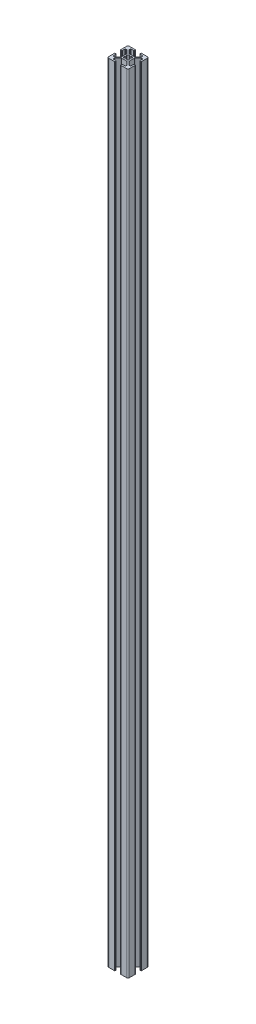
from build123d import *

# Parameters (mm, degrees)
C_PROGRAM_FILES_SOLIDWORKS_CORP_SOLIDWOR_DEPTH = 760


with BuildPart() as part:
    # Sketch11 → C_PROGRAM FILES_SOLIDWORKS CORP_SOLIDWOR (new body)
    with BuildSketch(Plane.XZ.offset(-380)):
        with BuildLine():
            Line((9.0094, 2.6289), (9.492, 2.6289))
            ThreePointArc((9.492, 2.6289), (9.851210245, 2.777689755), (10, 3.1369))
            Line((10, 3.1369), (10, 8.5014))
            ThreePointArc((10, 8.5014), (9.561070222, 9.561070222), (8.5014, 10))
            Line((8.5014, 10), (3.1369, 10))
            ThreePointArc((3.1369, 10), (2.777689755, 9.851210245), (2.6289, 9.492))
            Line((2.6289, 9.492), (2.6289, 9.0094))
            ThreePointArc((2.6289, 9.0094), (2.777689755, 8.650189755), (3.1369, 8.5014))
            Line((3.1369, 8.5014), (5.4864, 8.5014))
            ThreePointArc((5.4864, 8.5014), (5.845610245, 8.352610245), (5.9944, 7.9934))
            Line((5.9944, 7.9934), (5.9944, 7.264490712))
            ThreePointArc((5.9944, 7.264490712), (5.955730803, 7.070087528), (5.845610245, 6.905280467))
            Line((5.845610245, 6.905280467), (2.747686782, 3.807357004))
            ThreePointArc((2.747686782, 3.807357004), (2.582879721, 3.697236446), (2.388476537, 3.658567249))
            Line((2.388476537, 3.658567249), (-2.388476537, 3.658567249))
            ThreePointArc((-2.388476537, 3.658567249), (-2.582879721, 3.697236446), (-2.747686782, 3.807357004))
            Line((-2.747686782, 3.807357004), (-5.845610245, 6.905280467))
            ThreePointArc((-5.845610245, 6.905280467), (-5.955730803, 7.070087528), (-5.9944, 7.264490712))
            Line((-5.9944, 7.264490712), (-5.9944, 7.9934))
            ThreePointArc((-5.9944, 7.9934), (-5.845610245, 8.352610245), (-5.4864, 8.5014))
            Line((-5.4864, 8.5014), (-3.1369, 8.5014))
            ThreePointArc((-3.1369, 8.5014), (-2.777689755, 8.650189755), (-2.6289, 9.0094))
            Line((-2.6289, 9.0094), (-2.6289, 9.492))
            ThreePointArc((-2.6289, 9.492), (-2.777689755, 9.851210245), (-3.1369, 10))
            Line((-3.1369, 10), (-8.5014, 10))
            ThreePointArc((-8.5014, 10), (-9.561070222, 9.561070222), (-10, 8.5014))
            Line((-10, 8.5014), (-10, 3.1369))
            ThreePointArc((-10, 3.1369), (-9.851210245, 2.777689755), (-9.492, 2.6289))
            Line((-9.492, 2.6289), (-9.0094, 2.6289))
            ThreePointArc((-9.0094, 2.6289), (-8.650189755, 2.777689755), (-8.5014, 3.1369))
            Line((-8.5014, 3.1369), (-8.5014, 5.4864))
            ThreePointArc((-8.5014, 5.4864), (-8.352610245, 5.845610245), (-7.9934, 5.9944))
            Line((-7.9934, 5.9944), (-7.264490712, 5.9944))
            ThreePointArc((-7.264490712, 5.9944), (-7.070087528, 5.955730803), (-6.905280467, 5.845610245))
            Line((-6.905280467, 5.845610245), (-3.807357004, 2.747686782))
            ThreePointArc((-3.807357004, 2.747686782), (-3.697236446, 2.582879721), (-3.658567249, 2.388476537))
            Line((-3.658567249, 2.388476537), (-3.658567249, -2.388476537))
            ThreePointArc((-3.658567249, -2.388476537), (-3.697236446, -2.582879721), (-3.807357004, -2.747686782))
            Line((-3.807357004, -2.747686782), (-6.905280467, -5.845610245))
            ThreePointArc((-6.905280467, -5.845610245), (-7.070087528, -5.955730803), (-7.264490712, -5.9944))
            Line((-7.264490712, -5.9944), (-7.9934, -5.9944))
            ThreePointArc((-7.9934, -5.9944), (-8.352610245, -5.845610245), (-8.5014, -5.4864))
            Line((-8.5014, -5.4864), (-8.5014, -3.1369))
            ThreePointArc((-8.5014, -3.1369), (-8.650189755, -2.777689755), (-9.0094, -2.6289))
            Line((-9.0094, -2.6289), (-9.492, -2.6289))
            ThreePointArc((-9.492, -2.6289), (-9.851210245, -2.777689755), (-10, -3.1369))
            Line((-10, -3.1369), (-10, -8.5014))
            ThreePointArc((-10, -8.5014), (-9.561070222, -9.561070222), (-8.5014, -10))
            Line((-8.5014, -10), (-3.1369, -10))
            ThreePointArc((-3.1369, -10), (-2.777689755, -9.851210245), (-2.6289, -9.492))
            Line((-2.6289, -9.492), (-2.6289, -9.0094))
            ThreePointArc((-2.6289, -9.0094), (-2.777689755, -8.650189755), (-3.1369, -8.5014))
            Line((-3.1369, -8.5014), (-5.4864, -8.5014))
            ThreePointArc((-5.4864, -8.5014), (-5.845610245, -8.352610245), (-5.9944, -7.9934))
            Line((-5.9944, -7.9934), (-5.9944, -7.264490712))
            ThreePointArc((-5.9944, -7.264490712), (-5.955730803, -7.070087528), (-5.845610245, -6.905280467))
            Line((-5.845610245, -6.905280467), (-2.747686782, -3.807357004))
            ThreePointArc((-2.747686782, -3.807357004), (-2.582879721, -3.697236446), (-2.388476537, -3.658567249))
            Line((-2.388476537, -3.658567249), (2.388476537, -3.658567249))
            ThreePointArc((2.388476537, -3.658567249), (2.582879721, -3.697236446), (2.747686782, -3.807357004))
            Line((2.747686782, -3.807357004), (5.845610245, -6.905280467))
            ThreePointArc((5.845610245, -6.905280467), (5.955730803, -7.070087528), (5.9944, -7.264490712))
            Line((5.9944, -7.264490712), (5.9944, -7.9934))
            ThreePointArc((5.9944, -7.9934), (5.845610245, -8.352610245), (5.4864, -8.5014))
            Line((5.4864, -8.5014), (3.1369, -8.5014))
            ThreePointArc((3.1369, -8.5014), (2.777689755, -8.650189755), (2.6289, -9.0094))
            Line((2.6289, -9.0094), (2.6289, -9.492))
            ThreePointArc((2.6289, -9.492), (2.777689755, -9.851210245), (3.1369, -10))
            Line((3.1369, -10), (8.5014, -10))
            ThreePointArc((8.5014, -10), (9.561070222, -9.561070222), (10, -8.5014))
            Line((10, -8.5014), (10, -3.1369))
            ThreePointArc((10, -3.1369), (9.851210245, -2.777689755), (9.492, -2.6289))
            Line((9.492, -2.6289), (9.0094, -2.6289))
            ThreePointArc((9.0094, -2.6289), (8.650189755, -2.777689755), (8.5014, -3.1369))
            Line((8.5014, -3.1369), (8.5014, -5.4864))
            ThreePointArc((8.5014, -5.4864), (8.352610245, -5.845610245), (7.9934, -5.9944))
            Line((7.9934, -5.9944), (7.264490712, -5.9944))
            ThreePointArc((7.264490712, -5.9944), (7.070087528, -5.955730803), (6.905280467, -5.845610245))
            Line((6.905280467, -5.845610245), (3.807357004, -2.747686782))
            ThreePointArc((3.807357004, -2.747686782), (3.697236446, -2.582879721), (3.658567249, -2.388476537))
            Line((3.658567249, -2.388476537), (3.658567249, 2.388476537))
            ThreePointArc((3.658567249, 2.388476537), (3.697236446, 2.582879721), (3.807357004, 2.747686782))
            Line((3.807357004, 2.747686782), (6.905280467, 5.845610245))
            ThreePointArc((6.905280467, 5.845610245), (7.070087528, 5.955730803), (7.264490712, 5.9944))
            Line((7.264490712, 5.9944), (7.9934, 5.9944))
            ThreePointArc((7.9934, 5.9944), (8.352610245, 5.845610245), (8.5014, 5.4864))
            Line((8.5014, 5.4864), (8.5014, 3.1369))
            ThreePointArc((8.5014, 3.1369), (8.650189755, 2.777689755), (9.0094, 2.6289))
        make_face()
        with BuildLine():
            Line((-2.296558466, 2.121727546), (-2.121727546, 2.296558466))
            ThreePointArc((-2.121727546, 2.296558466), (-1.459775814, 2.520126613), (-0.880635441, 2.129282347))
            ThreePointArc((-0.880635441, 2.129282347), (-0.755121693, 2.019456424), (-0.588548999, 2.011151493))
            ThreePointArc((-0.588548999, 2.011151493), (0, 2.0955), (0.588548999, 2.011151493))
            ThreePointArc((0.588548999, 2.011151493), (0.755121693, 2.019456424), (0.880635441, 2.129282347))
            ThreePointArc((0.880635441, 2.129282347), (1.459775814, 2.520126613), (2.121727546, 2.296558466))
            Line((2.121727546, 2.296558466), (2.296558466, 2.121727546))
            ThreePointArc((2.296558466, 2.121727546), (2.520126613, 1.459775814), (2.129282347, 0.880635441))
            ThreePointArc((2.129282347, 0.880635441), (2.019456424, 0.755121693), (2.011151493, 0.588548999))
            ThreePointArc((2.011151493, 0.588548999), (2.0955, 0), (2.011151493, -0.588548999))
            ThreePointArc((2.011151493, -0.588548999), (2.019456424, -0.755121693), (2.129282347, -0.880635441))
            ThreePointArc((2.129282347, -0.880635441), (2.520126613, -1.459775814), (2.296558466, -2.121727546))
            Line((2.296558466, -2.121727546), (2.121727546, -2.296558466))
            ThreePointArc((2.121727546, -2.296558466), (1.459775814, -2.520126613), (0.880635441, -2.129282347))
            ThreePointArc((0.880635441, -2.129282347), (0.755121693, -2.019456424), (0.588548999, -2.011151493))
            ThreePointArc((0.588548999, -2.011151493), (0, -2.0955), (-0.588548999, -2.011151493))
            ThreePointArc((-0.588548999, -2.011151493), (-0.755121693, -2.019456424), (-0.880635441, -2.129282347))
            ThreePointArc((-0.880635441, -2.129282347), (-1.459775814, -2.520126613), (-2.121727546, -2.296558466))
            Line((-2.121727546, -2.296558466), (-2.296558466, -2.121727546))
            ThreePointArc((-2.296558466, -2.121727546), (-2.520126613, -1.459775814), (-2.129282347, -0.880635441))
            ThreePointArc((-2.129282347, -0.880635441), (-2.019456424, -0.755121693), (-2.011151493, -0.588548999))
            ThreePointArc((-2.011151493, -0.588548999), (-2.0955, 0), (-2.011151493, 0.588548999))
            ThreePointArc((-2.011151493, 0.588548999), (-2.019456424, 0.755121693), (-2.129282347, 0.880635441))
            ThreePointArc((-2.129282347, 0.880635441), (-2.520126613, 1.459775814), (-2.296558466, 2.121727546))
        make_face(mode=Mode.SUBTRACT)
    extrude(amount=C_PROGRAM_FILES_SOLIDWORKS_CORP_SOLIDWOR_DEPTH)


solid = part.part
